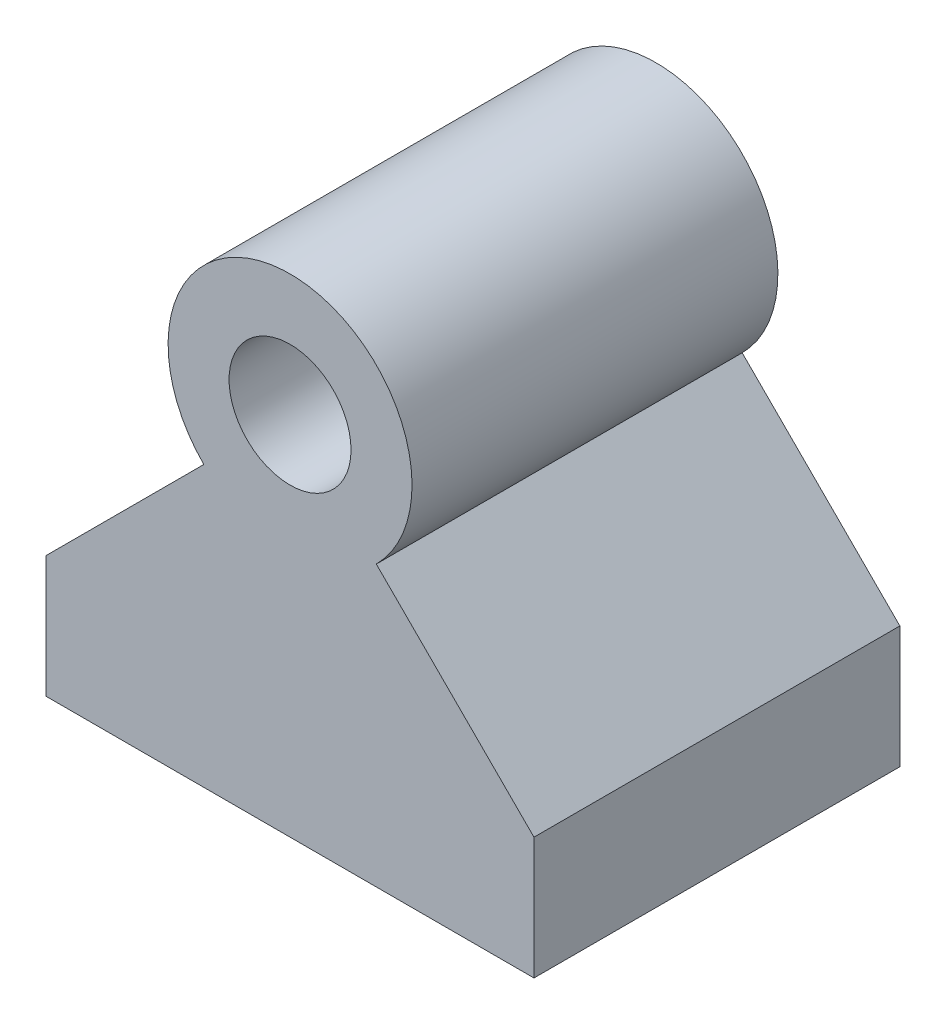
from build123d import *

# Parameters (mm, degrees)
ESBO_O1_R                = 5
RESSALTO_EXTRUS_O1_DEPTH = 15


with BuildPart() as part:
    # Esboço1 → Ressalto-extrusão1 (new body, symmetric)
    with BuildSketch(Plane.XY):
        with BuildLine():
            Line((-20, 0), (20, 0))
            Line((20, 0), (20, 10))
            Line((20, 10), (7.071067812, 22.928932188))
            ThreePointArc((7.071067812, 22.928932188), (0, 40), (-7.071067812, 22.928932188))
            Line((-7.071067812, 22.928932188), (-20, 10))
            Line((-20, 10), (-20, 0))
        make_face()
        with Locations((0, 30)):
            Circle(ESBO_O1_R, mode=Mode.SUBTRACT)
    extrude(amount=RESSALTO_EXTRUS_O1_DEPTH, both=True)


solid = part.part
